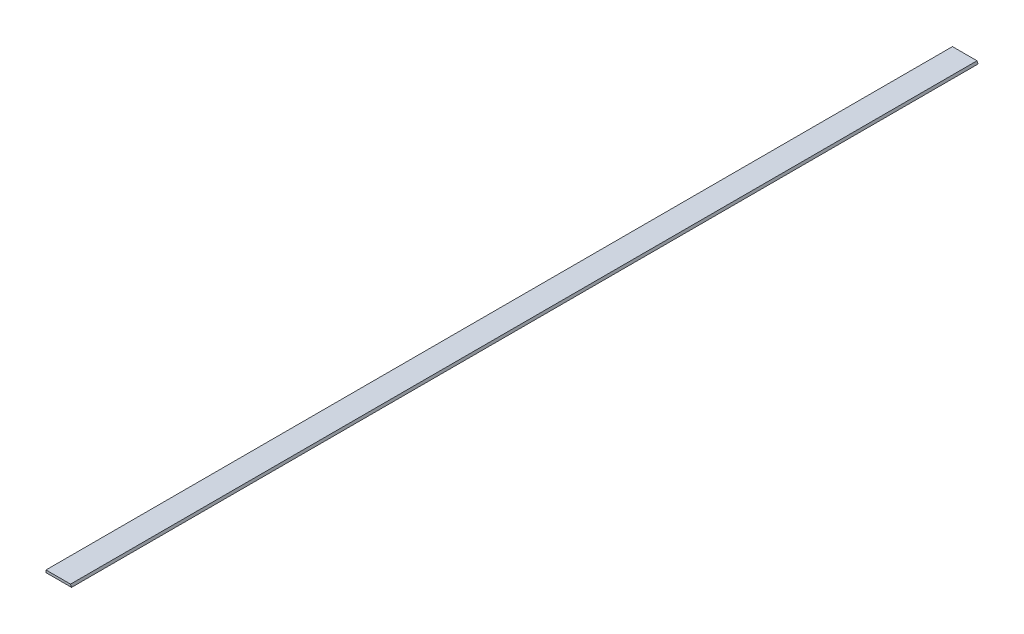
from build123d import *

# Parameters (mm, degrees)
BOSS_EXTRUDE1_DEPTH = 901.7


with BuildPart() as part:
    # Sketch1 → Boss-Extrude1 (new body)
    with BuildSketch(Plane.XY):
        Polygon((0, 0), (0, 2.3622), (24.421544723, 2.3622), (25.4, 0), align=None)
    extrude(amount=BOSS_EXTRUDE1_DEPTH)


solid = part.part
